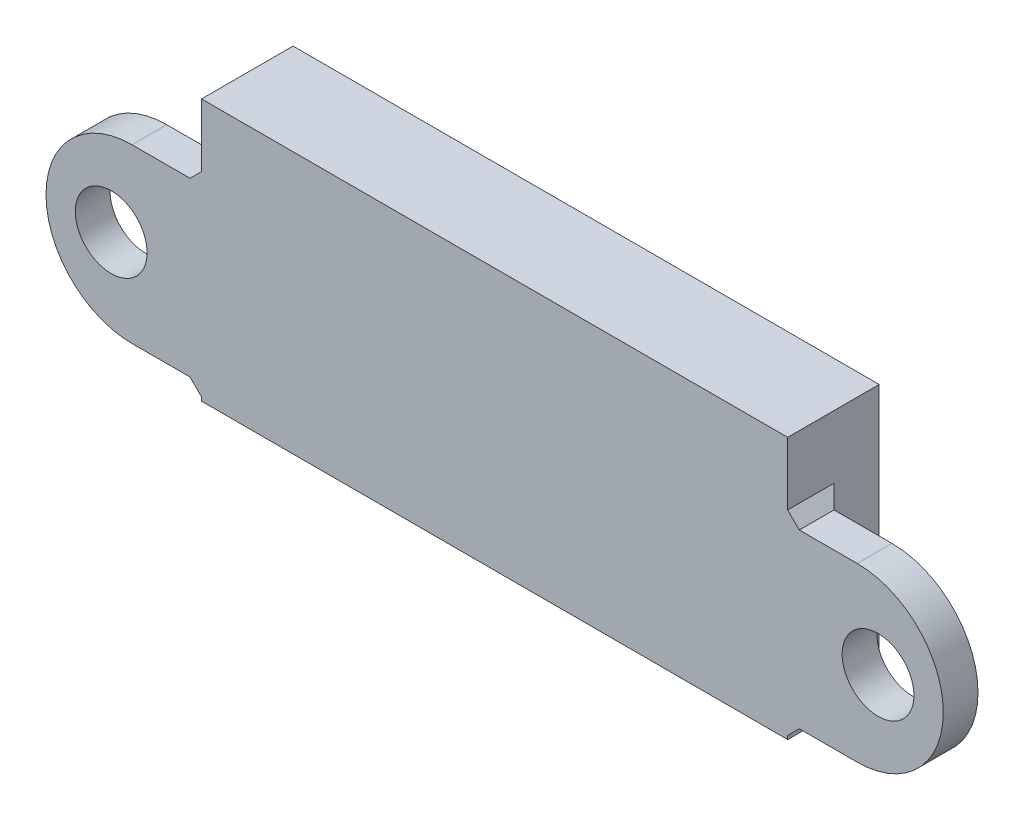
from build123d import *

# Parameters (mm, degrees)
BOSS_EXTRUDE1_DEPTH = 5
SKETCH2_W           = 50.6
SKETCH2_H           = 22.6
SKETCH2_W_2         = 48
SKETCH2_H_2         = 20
BOSS_EXTRUDE2_DEPTH = 7.9
SKETCH3_R           = 1.1
CUT_EXTRUDE1_DEPTH  = 3
BOSS_EXTRUDE3_DEPTH = 3
CHAMFER1_SIZE       = 1
SKETCH5_R           = 3.1
CUT_EXTRUDE2_DEPTH  = 3


with BuildPart() as part:
    # Sketch1 → Boss-Extrude1 (new body)
    with BuildSketch(Plane.XY):
        Polygon((24, 12.55), (6.08, 12.55), (-6.08, 12.55), (-24, 12.55), (-24, -7.45), (24, -7.45), align=None)
    extrude(amount=BOSS_EXTRUDE1_DEPTH)

    # Sketch2 → Boss-Extrude2 (add)
    with BuildSketch(Plane.XY.offset(5)):
        with Locations((0, 2.55)):
            Rectangle(SKETCH2_W, SKETCH2_H)
        with Locations((0, 2.55)):
            Rectangle(SKETCH2_W_2, SKETCH2_H_2, mode=Mode.SUBTRACT)
    extrude(amount=-BOSS_EXTRUDE2_DEPTH)

    # Sketch3 → Cut-Extrude1 (cut)
    with BuildSketch(Plane(origin=(0, 0, 0), x_dir=(-1, 0, 0), z_dir=(0, 0, -1))):
        with Locations((-18.5, 0)):
            Circle(SKETCH3_R)
        with Locations((18.5, 0)):
            Circle(SKETCH3_R)
    extrude(amount=-CUT_EXTRUDE1_DEPTH, mode=Mode.SUBTRACT)

    # Sketch4 → Boss-Extrude3 (add)
    with BuildSketch(Plane.XY.offset(5)):
        with BuildLine():
            Line((25.3, -7.439559179), (31.3, -7.439559179))
            ThreePointArc((31.3, -7.439559179), (38.729997149, -0.00956203), (31.3, 7.42043512))
            Line((31.3, 7.42043512), (25.3, 7.42043512))
            Line((25.3, 7.42043512), (25.3, -7.439559179))
        make_face()
        with BuildLine():
            Line((-25.3, -7.439559179), (-31.3, -7.439559179))
            ThreePointArc((-31.3, -7.439559179), (-38.729997149, -0.00956203), (-31.3, 7.42043512))
            Line((-31.3, 7.42043512), (-25.3, 7.42043512))
            Line((-25.3, 7.42043512), (-25.3, -7.439559179))
        make_face()
    extrude(amount=-BOSS_EXTRUDE3_DEPTH)

    # Chamfer1
    chamfer1_edges = [part.edges().sort_by_distance(p)[0] for p in [
        (25.3, -0.00956203, 2),
        (25.3, -7.439559179, 3.5),
        (25.3, 7.42043512, 3.5),
        (-25.3, -0.00956203, 2),
        (-25.3, 7.42043512, 3.5),
        (-25.3, -7.439559179, 3.5),
    ]]
    chamfer(chamfer1_edges, length=CHAMFER1_SIZE)

    # Sketch5 → Cut-Extrude2 (cut)
    with BuildSketch(Plane(origin=(0, 0, 2), x_dir=(-1, 0, 0), z_dir=(0, 0, -1))):
        with Locations((-33.1, -0.00956203)):
            Circle(SKETCH5_R)
        with Locations((33.1, -0.00956203)):
            Circle(SKETCH5_R)
    extrude(amount=-CUT_EXTRUDE2_DEPTH, mode=Mode.SUBTRACT)


solid = part.part
